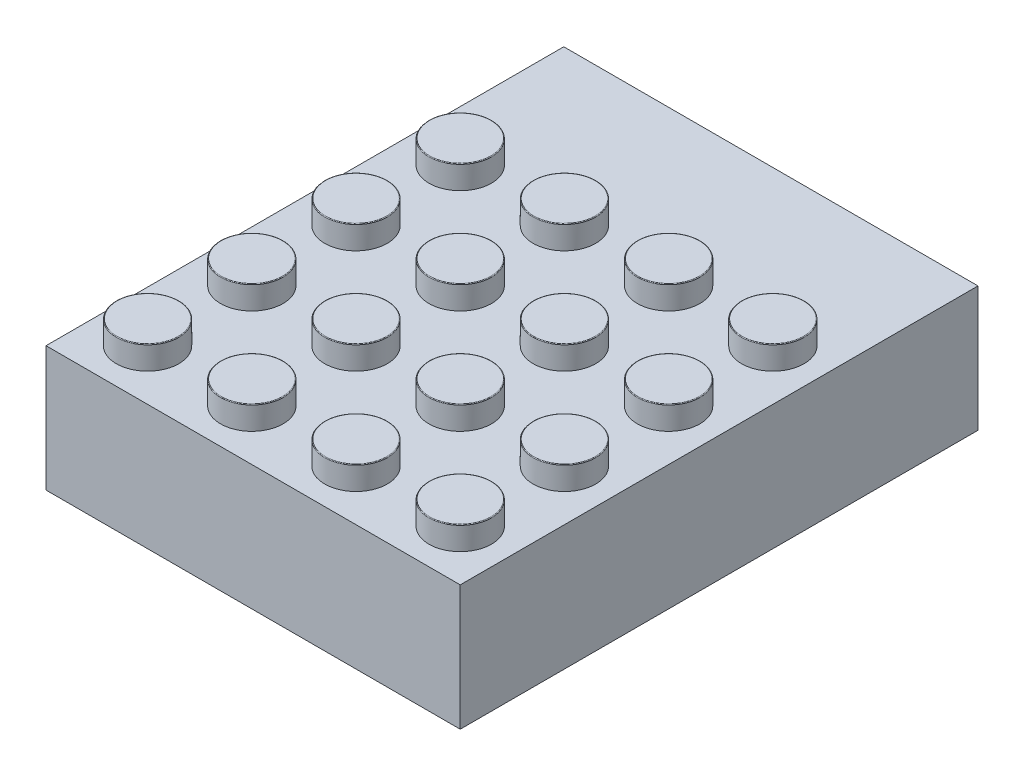
from build123d import *

# Parameters (mm, degrees)
SKETCH1_W                 = 31.8
SKETCH1_H                 = 39.75
BOSS_EXTRUDE1_DEPTH       = 9.6
SKETCH2_R                 = 2.4
BOSS_EXTRUDE2_DEPTH       = 1.8
LPATTERN1_COUNT           = 4
LPATTERN1_PITCH           = 8
LPATTERN2_COUNT           = 4
LPATTERN2_PITCH           = 8
LPATTERN2_COPY_1_SKETCH_R = 2.4
LPATTERN2_COPY_1_DEPTH    = 1.8
LPATTERN2_COPY_2_SKETCH_R = 2.4
LPATTERN2_COPY_2_DEPTH    = 1.8
LPATTERN2_COPY_3_SKETCH_R = 2.4
LPATTERN2_COPY_3_DEPTH    = 1.8
LPATTERN2_COPY_4_SKETCH_R = 2.4
LPATTERN2_COPY_4_DEPTH    = 1.8
LPATTERN2_COPY_5_SKETCH_R = 2.4
LPATTERN2_COPY_5_DEPTH    = 1.8
LPATTERN2_COPY_6_SKETCH_R = 2.4
LPATTERN2_COPY_6_DEPTH    = 1.8
LPATTERN2_COPY_7_SKETCH_R = 2.4
LPATTERN2_COPY_7_DEPTH    = 1.8
LPATTERN2_COPY_8_SKETCH_R = 2.4
LPATTERN2_COPY_8_DEPTH    = 1.8
LPATTERN2_COPY_9_SKETCH_R = 2.4
LPATTERN2_COPY_9_DEPTH    = 1.8
FILLET1_R                 = 0.05
SKETCH3_W                 = 29.4
SKETCH3_H                 = 37.35
CUT_EXTRUDE1_DEPTH        = 6.8
SKETCH4_R                 = 3.2125
BOSS_EXTRUDE3_DEPTH       = 6.8
SKETCH5_R                 = 2.25
CUT_EXTRUDE2_DEPTH        = 6.8
LPATTERN3_COUNT           = 3
LPATTERN3_PITCH           = 8
LPATTERN4_COUNT           = 3
LPATTERN4_PITCH           = 8
LPATTERN4_COPY_1_SKETCH_R = 3.2125
LPATTERN4_COPY_1_DEPTH    = 6.8
LPATTERN4_COPY_2_SKETCH_R = 3.2125
LPATTERN4_COPY_2_DEPTH    = 6.8
LPATTERN4_COPY_3_SKETCH_R = 3.2125
LPATTERN4_COPY_3_DEPTH    = 6.8
LPATTERN4_COPY_4_SKETCH_R = 3.2125
LPATTERN4_COPY_4_DEPTH    = 6.8
LPATTERN4_COPY_5_SKETCH_R = 2.25
LPATTERN4_COPY_5_DEPTH    = 6.8
LPATTERN4_COPY_6_SKETCH_R = 2.25
LPATTERN4_COPY_6_DEPTH    = 6.8
LPATTERN4_COPY_7_SKETCH_R = 2.25
LPATTERN4_COPY_7_DEPTH    = 6.8
LPATTERN4_COPY_8_SKETCH_R = 2.25
LPATTERN4_COPY_8_DEPTH    = 6.8
LPATTERN5_COUNT           = 2
LPATTERN5_PITCH           = 8
LPATTERN5_COPY_1_SKETCH_R = 3.2125
LPATTERN5_COPY_1_DEPTH    = 6.8
LPATTERN5_COPY_2_SKETCH_R = 3.2125
LPATTERN5_COPY_2_DEPTH    = 6.8
LPATTERN5_COPY_3_SKETCH_R = 2.25
LPATTERN5_COPY_3_DEPTH    = 6.8
LPATTERN5_COPY_4_SKETCH_R = 2.25
LPATTERN5_COPY_4_DEPTH    = 6.8
SKETCH6_W                 = 0.3
SKETCH6_H                 = 0.6
BOSS_EXTRUDE4_DEPTH       = 6.8
SKETCH7_W                 = 0.6
SKETCH7_H                 = 0.3
BOSS_EXTRUDE5_DEPTH       = 6.8


with BuildPart() as part:
    # Sketch1 → Boss-Extrude1 (new body)
    with BuildSketch(Plane(origin=(0, 0, 0), x_dir=(1, 0, 0), z_dir=(0, 1, 0))):
        Rectangle(SKETCH1_W, SKETCH1_H)
    extrude(amount=BOSS_EXTRUDE1_DEPTH)

    # Sketch2 → Boss-Extrude2 (add)
    with BuildSketch(Plane(origin=(0, 9.6, 0), x_dir=(1, 0, 0), z_dir=(0, 1, 0))):
        with Locations((-12, -15.975)):
            Circle(SKETCH2_R)
    boss_extrude2 = extrude(amount=BOSS_EXTRUDE2_DEPTH)

    # LPattern1: Boss-Extrude2 ×4
    with Locations(*[(0, 0, -i * LPATTERN1_PITCH) for i in range(1, LPATTERN1_COUNT)]):
        add(boss_extrude2)

    # LPattern2: Boss-Extrude2 ×4
    with Locations(*[(i * LPATTERN2_PITCH, 0, 0) for i in range(1, LPATTERN2_COUNT)]):
        add(boss_extrude2)

    # LPattern2 copy 1 sketch → LPattern2 copy 1 (add)
    with BuildSketch(Plane(origin=(8, 9.6, -8), x_dir=(1, 0, 0), z_dir=(0, 1, 0))):
        with Locations((-12, -15.975)):
            Circle(LPATTERN2_COPY_1_SKETCH_R)
    extrude(amount=LPATTERN2_COPY_1_DEPTH)

    # LPattern2 copy 2 sketch → LPattern2 copy 2 (add)
    with BuildSketch(Plane(origin=(16, 9.6, -8), x_dir=(1, 0, 0), z_dir=(0, 1, 0))):
        with Locations((-12, -15.975)):
            Circle(LPATTERN2_COPY_2_SKETCH_R)
    extrude(amount=LPATTERN2_COPY_2_DEPTH)

    # LPattern2 copy 3 sketch → LPattern2 copy 3 (add)
    with BuildSketch(Plane(origin=(24, 9.6, -8), x_dir=(1, 0, 0), z_dir=(0, 1, 0))):
        with Locations((-12, -15.975)):
            Circle(LPATTERN2_COPY_3_SKETCH_R)
    extrude(amount=LPATTERN2_COPY_3_DEPTH)

    # LPattern2 copy 4 sketch → LPattern2 copy 4 (add)
    with BuildSketch(Plane(origin=(8, 9.6, -16), x_dir=(1, 0, 0), z_dir=(0, 1, 0))):
        with Locations((-12, -15.975)):
            Circle(LPATTERN2_COPY_4_SKETCH_R)
    extrude(amount=LPATTERN2_COPY_4_DEPTH)

    # LPattern2 copy 5 sketch → LPattern2 copy 5 (add)
    with BuildSketch(Plane(origin=(16, 9.6, -16), x_dir=(1, 0, 0), z_dir=(0, 1, 0))):
        with Locations((-12, -15.975)):
            Circle(LPATTERN2_COPY_5_SKETCH_R)
    extrude(amount=LPATTERN2_COPY_5_DEPTH)

    # LPattern2 copy 6 sketch → LPattern2 copy 6 (add)
    with BuildSketch(Plane(origin=(24, 9.6, -16), x_dir=(1, 0, 0), z_dir=(0, 1, 0))):
        with Locations((-12, -15.975)):
            Circle(LPATTERN2_COPY_6_SKETCH_R)
    extrude(amount=LPATTERN2_COPY_6_DEPTH)

    # LPattern2 copy 7 sketch → LPattern2 copy 7 (add)
    with BuildSketch(Plane(origin=(8, 9.6, -24), x_dir=(1, 0, 0), z_dir=(0, 1, 0))):
        with Locations((-12, -15.975)):
            Circle(LPATTERN2_COPY_7_SKETCH_R)
    extrude(amount=LPATTERN2_COPY_7_DEPTH)

    # LPattern2 copy 8 sketch → LPattern2 copy 8 (add)
    with BuildSketch(Plane(origin=(16, 9.6, -24), x_dir=(1, 0, 0), z_dir=(0, 1, 0))):
        with Locations((-12, -15.975)):
            Circle(LPATTERN2_COPY_8_SKETCH_R)
    extrude(amount=LPATTERN2_COPY_8_DEPTH)

    # LPattern2 copy 9 sketch → LPattern2 copy 9 (add)
    with BuildSketch(Plane(origin=(24, 9.6, -24), x_dir=(1, 0, 0), z_dir=(0, 1, 0))):
        with Locations((-12, -15.975)):
            Circle(LPATTERN2_COPY_9_SKETCH_R)
    extrude(amount=LPATTERN2_COPY_9_DEPTH)

    # Fillet1
    fillet1_edges = [part.edges().sort_by_distance(p)[0] for p in [
        (-14.4, 11.4, 15.975),
        (-14.4, 11.4, 7.975),
        (-14.4, 11.4, -0.025),
        (-14.4, 11.4, -8.025),
        (-6.4, 11.4, 7.975),
        (1.6, 11.4, 7.975),
        (9.6, 11.4, 7.975),
        (-6.4, 11.4, 15.975),
        (1.6, 11.4, 15.975),
        (9.6, 11.4, 15.975),
        (-6.4, 11.4, -8.025),
        (1.6, 11.4, -8.025),
        (9.6, 11.4, -8.025),
        (-6.4, 11.4, -0.025),
        (1.6, 11.4, -0.025),
        (9.6, 11.4, -0.025),
    ]]
    fillet(fillet1_edges, radius=FILLET1_R)

    # Sketch3 → Cut-Extrude1 (cut)
    with BuildSketch(Plane(origin=(0, 0, 0), x_dir=(-1, 0, 0), z_dir=(0, -1, 0))):
        Rectangle(SKETCH3_W, SKETCH3_H)
    extrude(amount=-CUT_EXTRUDE1_DEPTH, mode=Mode.SUBTRACT)

    # Sketch4 → Boss-Extrude3 (add)
    with BuildSketch(Plane(origin=(0, 6.8, 0), x_dir=(-1, 0, 0), z_dir=(0, -1, 0))):
        with Locations((-8, 4.025)):
            Circle(SKETCH4_R)
    boss_extrude3 = extrude(amount=BOSS_EXTRUDE3_DEPTH)

    # Sketch5 → Cut-Extrude2 (cut)
    with BuildSketch(Plane(origin=(0, 0, 0), x_dir=(-1, 0, 0), z_dir=(0, -1, 0))):
        with Locations((-8, 4.025)):
            Circle(SKETCH5_R)
    cut_extrude2 = extrude(amount=-CUT_EXTRUDE2_DEPTH, mode=Mode.SUBTRACT)

    # LPattern3: Boss-Extrude3, Cut-Extrude2 ×3
    with Locations(*[(-i * LPATTERN3_PITCH, 0, 0) for i in range(1, LPATTERN3_COUNT)]):
        add(boss_extrude3)
        add(cut_extrude2, mode=Mode.SUBTRACT)

    # LPattern4: Boss-Extrude3, Cut-Extrude2 ×3
    with Locations(*[(0, 0, i * LPATTERN4_PITCH) for i in range(1, LPATTERN4_COUNT)]):
        add(boss_extrude3)
        add(cut_extrude2, mode=Mode.SUBTRACT)

    # LPattern4 copy 1 sketch → LPattern4 copy 1 (add)
    with BuildSketch(Plane(origin=(-8, 6.8, 8), x_dir=(-1, 0, 0), z_dir=(0, -1, 0))):
        with Locations((-8, 4.025)):
            Circle(LPATTERN4_COPY_1_SKETCH_R)
    extrude(amount=LPATTERN4_COPY_1_DEPTH)

    # LPattern4 copy 2 sketch → LPattern4 copy 2 (add)
    with BuildSketch(Plane(origin=(-8, 6.8, 16), x_dir=(-1, 0, 0), z_dir=(0, -1, 0))):
        with Locations((-8, 4.025)):
            Circle(LPATTERN4_COPY_2_SKETCH_R)
    extrude(amount=LPATTERN4_COPY_2_DEPTH)

    # LPattern4 copy 3 sketch → LPattern4 copy 3 (add)
    with BuildSketch(Plane(origin=(-16, 6.8, 8), x_dir=(-1, 0, 0), z_dir=(0, -1, 0))):
        with Locations((-8, 4.025)):
            Circle(LPATTERN4_COPY_3_SKETCH_R)
    extrude(amount=LPATTERN4_COPY_3_DEPTH)

    # LPattern4 copy 4 sketch → LPattern4 copy 4 (add)
    with BuildSketch(Plane(origin=(-16, 6.8, 16), x_dir=(-1, 0, 0), z_dir=(0, -1, 0))):
        with Locations((-8, 4.025)):
            Circle(LPATTERN4_COPY_4_SKETCH_R)
    extrude(amount=LPATTERN4_COPY_4_DEPTH)

    # LPattern4 copy 5 sketch → LPattern4 copy 5 (cut)
    with BuildSketch(Plane(origin=(-8, 0, 8), x_dir=(-1, 0, 0), z_dir=(0, -1, 0))):
        with Locations((-8, 4.025)):
            Circle(LPATTERN4_COPY_5_SKETCH_R)
    extrude(amount=-LPATTERN4_COPY_5_DEPTH, mode=Mode.SUBTRACT)

    # LPattern4 copy 6 sketch → LPattern4 copy 6 (cut)
    with BuildSketch(Plane(origin=(-8, 0, 16), x_dir=(-1, 0, 0), z_dir=(0, -1, 0))):
        with Locations((-8, 4.025)):
            Circle(LPATTERN4_COPY_6_SKETCH_R)
    extrude(amount=-LPATTERN4_COPY_6_DEPTH, mode=Mode.SUBTRACT)

    # LPattern4 copy 7 sketch → LPattern4 copy 7 (cut)
    with BuildSketch(Plane(origin=(-16, 0, 8), x_dir=(-1, 0, 0), z_dir=(0, -1, 0))):
        with Locations((-8, 4.025)):
            Circle(LPATTERN4_COPY_7_SKETCH_R)
    extrude(amount=-LPATTERN4_COPY_7_DEPTH, mode=Mode.SUBTRACT)

    # LPattern4 copy 8 sketch → LPattern4 copy 8 (cut)
    with BuildSketch(Plane(origin=(-16, 0, 16), x_dir=(-1, 0, 0), z_dir=(0, -1, 0))):
        with Locations((-8, 4.025)):
            Circle(LPATTERN4_COPY_8_SKETCH_R)
    extrude(amount=-LPATTERN4_COPY_8_DEPTH, mode=Mode.SUBTRACT)

    # LPattern5: Boss-Extrude3, Cut-Extrude2 ×2
    with Locations(*[(0, 0, -i * LPATTERN5_PITCH) for i in range(1, LPATTERN5_COUNT)]):
        add(boss_extrude3)
        add(cut_extrude2, mode=Mode.SUBTRACT)

    # LPattern5 copy 1 sketch → LPattern5 copy 1 (add)
    with BuildSketch(Plane(origin=(-8, 6.8, -8), x_dir=(-1, 0, 0), z_dir=(0, -1, 0))):
        with Locations((-8, 4.025)):
            Circle(LPATTERN5_COPY_1_SKETCH_R)
    extrude(amount=LPATTERN5_COPY_1_DEPTH)

    # LPattern5 copy 2 sketch → LPattern5 copy 2 (add)
    with BuildSketch(Plane(origin=(-16, 6.8, -8), x_dir=(-1, 0, 0), z_dir=(0, -1, 0))):
        with Locations((-8, 4.025)):
            Circle(LPATTERN5_COPY_2_SKETCH_R)
    extrude(amount=LPATTERN5_COPY_2_DEPTH)

    # LPattern5 copy 3 sketch → LPattern5 copy 3 (cut)
    with BuildSketch(Plane(origin=(-8, 0, -8), x_dir=(-1, 0, 0), z_dir=(0, -1, 0))):
        with Locations((-8, 4.025)):
            Circle(LPATTERN5_COPY_3_SKETCH_R)
    extrude(amount=-LPATTERN5_COPY_3_DEPTH, mode=Mode.SUBTRACT)

    # LPattern5 copy 4 sketch → LPattern5 copy 4 (cut)
    with BuildSketch(Plane(origin=(-16, 0, -8), x_dir=(-1, 0, 0), z_dir=(0, -1, 0))):
        with Locations((-8, 4.025)):
            Circle(LPATTERN5_COPY_4_SKETCH_R)
    extrude(amount=-LPATTERN5_COPY_4_DEPTH, mode=Mode.SUBTRACT)

    # Sketch6 → Boss-Extrude4 (add)
    with BuildSketch(Plane(origin=(0, 0, 0), x_dir=(-1, 0, 0), z_dir=(0, -1, 0))):
        with Locations((14.55, -15.975)):
            Rectangle(SKETCH6_W, SKETCH6_H)
        with Locations((14.55, -7.975)):
            Rectangle(SKETCH6_W, SKETCH6_H)
        with Locations((14.55, 0.025)):
            Rectangle(SKETCH6_W, SKETCH6_H)
        with Locations((14.55, 15.975)):
            Rectangle(SKETCH6_W, SKETCH6_H)
        with Locations((14.55, 8.025)):
            Rectangle(SKETCH6_W, SKETCH6_H)
    boss_extrude4 = extrude(amount=-BOSS_EXTRUDE4_DEPTH)

    # Mirror1: Boss-Extrude4 across plane
    add(boss_extrude4.mirror(Plane(origin=(0, 0, 0), x_dir=(0, 0, 1), z_dir=(1, 0, 0))))

    # Sketch7 → Boss-Extrude5 (add)
    with BuildSketch(Plane.XZ):
        with Locations((-12, 18.525)):
            Rectangle(SKETCH7_W, SKETCH7_H)
        with Locations((-4, 18.525)):
            Rectangle(SKETCH7_W, SKETCH7_H)
        with Locations((4, 18.525)):
            Rectangle(SKETCH7_W, SKETCH7_H)
        with Locations((12, 18.525)):
            Rectangle(SKETCH7_W, SKETCH7_H)
    boss_extrude5 = extrude(amount=-BOSS_EXTRUDE5_DEPTH)

    # Mirror2: Boss-Extrude5 across plane
    add(boss_extrude5.mirror(Plane.XY))


solid = part.part
